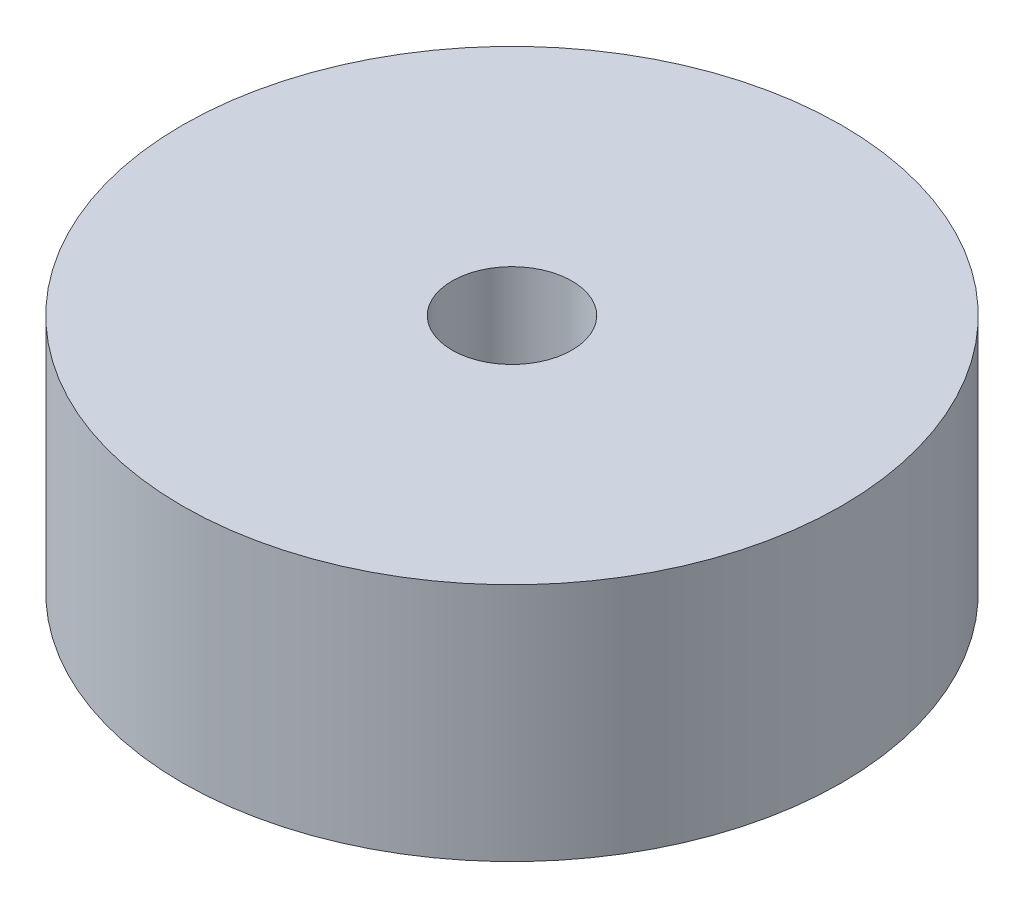
from build123d import *

# Parameters (mm, degrees)
SKETCH1_R           = 34.925
SKETCH1_R_2         = 6.35
BOSS_EXTRUDE1_DEPTH = 25.4


with BuildPart() as part:
    # Sketch1 → Boss-Extrude1 (new body)
    with BuildSketch(Plane(origin=(0, 0, 0), x_dir=(1, 0, 0), z_dir=(0, 1, 0))):
        Circle(SKETCH1_R)
        Circle(SKETCH1_R_2, mode=Mode.SUBTRACT)
    extrude(amount=BOSS_EXTRUDE1_DEPTH)


solid = part.part
